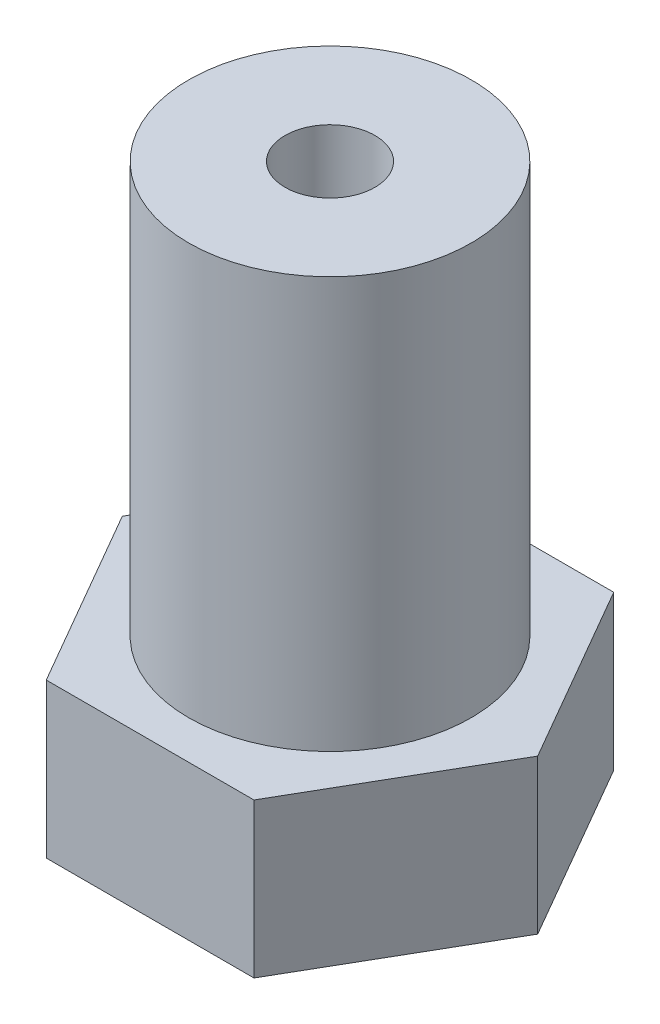
from build123d import *

# Parameters (mm, degrees)
BOSS_EXTRUDE1_DEPTH = 6
SKETCH2_R           = 5.5
SKETCH2_R_2         = 1.75
BOSS_EXTRUDE2_DEPTH = 16


with BuildPart() as part:
    # Sketch1 → Boss-Extrude1 (new body)
    with BuildSketch(Plane(origin=(0, 0, 0), x_dir=(1, 0, 0), z_dir=(0, 1, 0))):
        Polygon((8.082903769, 0), (4.041451884, 7), (-4.041451884, 7), (-8.082903769, 0), (-4.041451884, -7), (4.041451884, -7), align=None)
    extrude(amount=BOSS_EXTRUDE1_DEPTH)

    # Sketch2 → Boss-Extrude2 (add)
    with BuildSketch(Plane(origin=(0, 6, 0), x_dir=(1, 0, 0), z_dir=(0, 1, 0))):
        Circle(SKETCH2_R)
        Circle(SKETCH2_R_2, mode=Mode.SUBTRACT)
    extrude(amount=BOSS_EXTRUDE2_DEPTH)


solid = part.part
